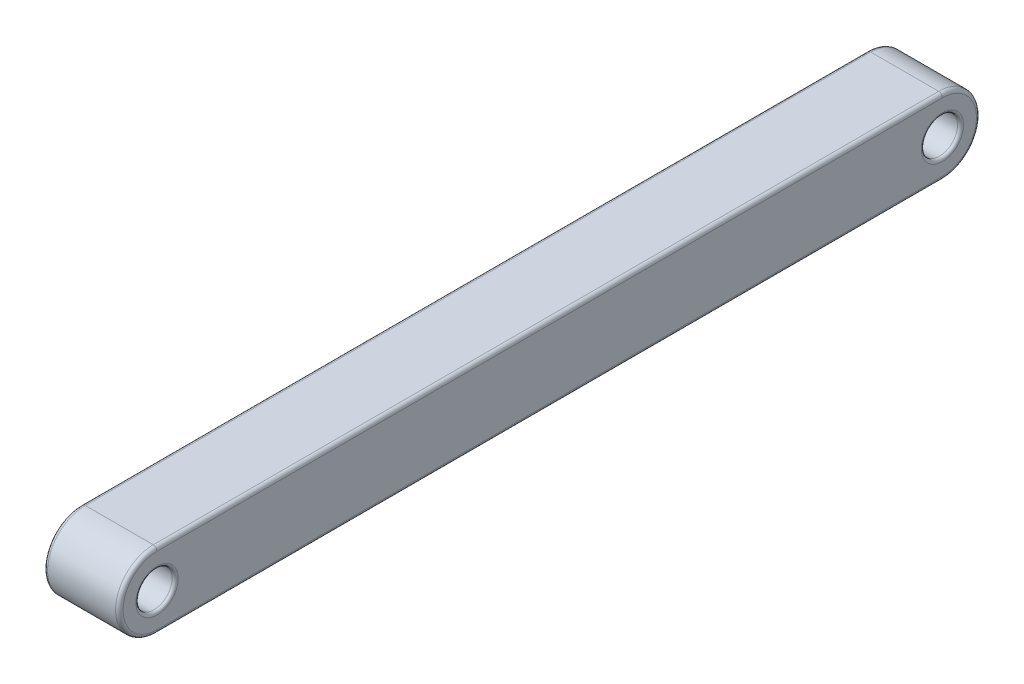
from build123d import *

# Parameters (mm, degrees)
SKETCH1_R           = 0.6
BOSS_EXTRUDE1_DEPTH = 2.5
FILLET1_R           = 0.125
FILLET2_R           = 0.1


with BuildPart() as part:
    # Sketch1 → Boss-Extrude1 (new body)
    with BuildSketch(Plane(origin=(0, 0, 0), x_dir=(0, 0, -1), z_dir=(1, 0, 0))):
        with BuildLine():
            ThreePointArc((25, 0), (26.25, -1.25), (25, -2.5))
            Line((25, -2.5), (24, -2.5))
            Line((24, -2.5), (0, -2.5))
            Line((0, -2.5), (-1, -2.5))
            ThreePointArc((-1, -2.5), (-2.25, -1.25), (-1, 0))
            Line((-1, 0), (0, 0))
            Line((0, 0), (24, 0))
            Line((24, 0), (25, 0))
        make_face()
        with Locations((25, -1.25)):
            Circle(SKETCH1_R, mode=Mode.SUBTRACT)
        with Locations((-1, -1.25)):
            Circle(SKETCH1_R, mode=Mode.SUBTRACT)
    extrude(amount=BOSS_EXTRUDE1_DEPTH)

    # Fillet1
    fillet1_edges = [part.edges().sort_by_distance(p)[0] for p in [
        (0, -1.25, 2.25),
        (0, 0, -12),
        (0, -1.25, -26.25),
        (2.5, 0, -12),
        (2.5, -1.25, 2.25),
        (2.5, -2.5, -12),
        (2.5, -1.25, -26.25),
        (0, -2.5, -12),
    ]]
    fillet(fillet1_edges, radius=FILLET1_R)

    # Fillet2
    fillet2_edges = [part.edges().sort_by_distance(p)[0] for p in [
        (2.5, -1.25, -24.4),
        (2.5, -1.25, 1.6),
        (0, -1.25, 1.6),
        (0, -1.25, -24.4),
    ]]
    fillet(fillet2_edges, radius=FILLET2_R)


solid = part.part
